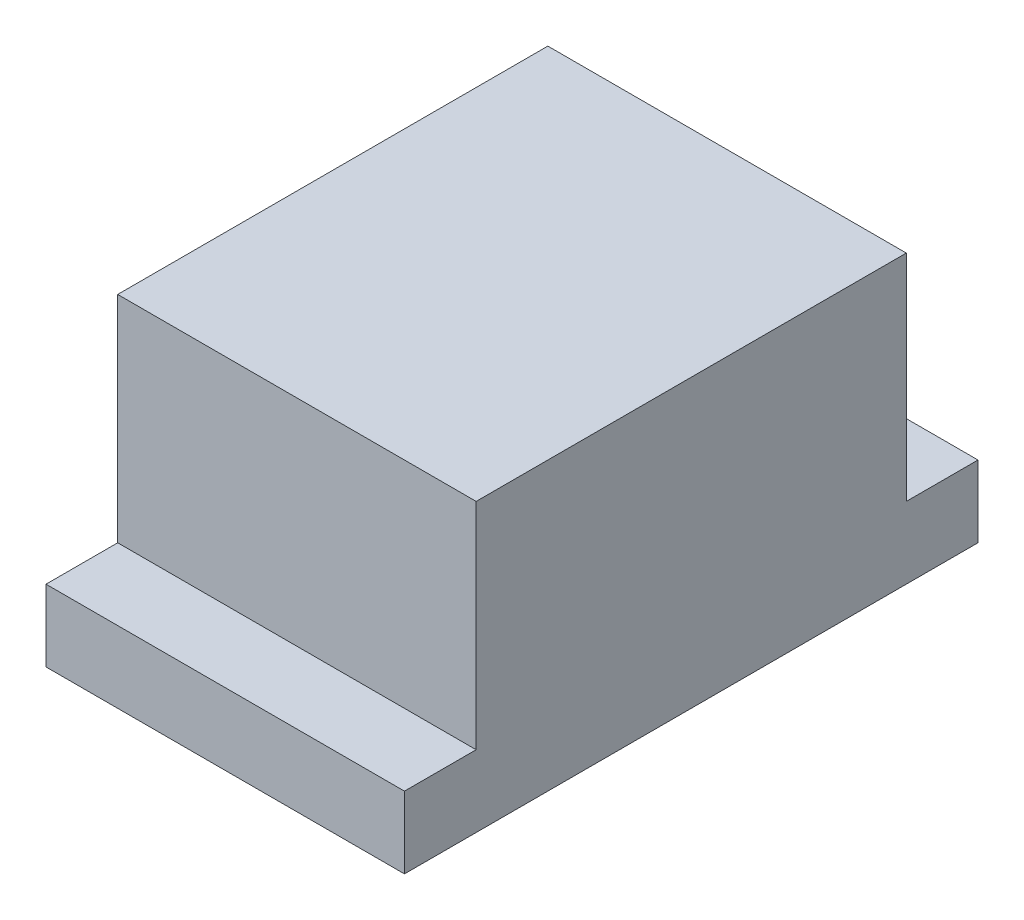
from build123d import *

# Parameters (mm, degrees)
EXTRUDE_1_DEPTH = 50


with BuildPart() as part:
    # 스케치2 → 보스-돌출1 (new body)
    with BuildSketch(Plane(origin=(0, 0, 0), x_dir=(0, 0, -1), z_dir=(1, 0, 0))):
        Polygon((-30, 40), (30, 40), (30, 10), (40, 10), (40, 0), (-40, 0), (-40, 10), (-30, 10), align=None)
    extrude(amount=EXTRUDE_1_DEPTH)


solid = part.part
